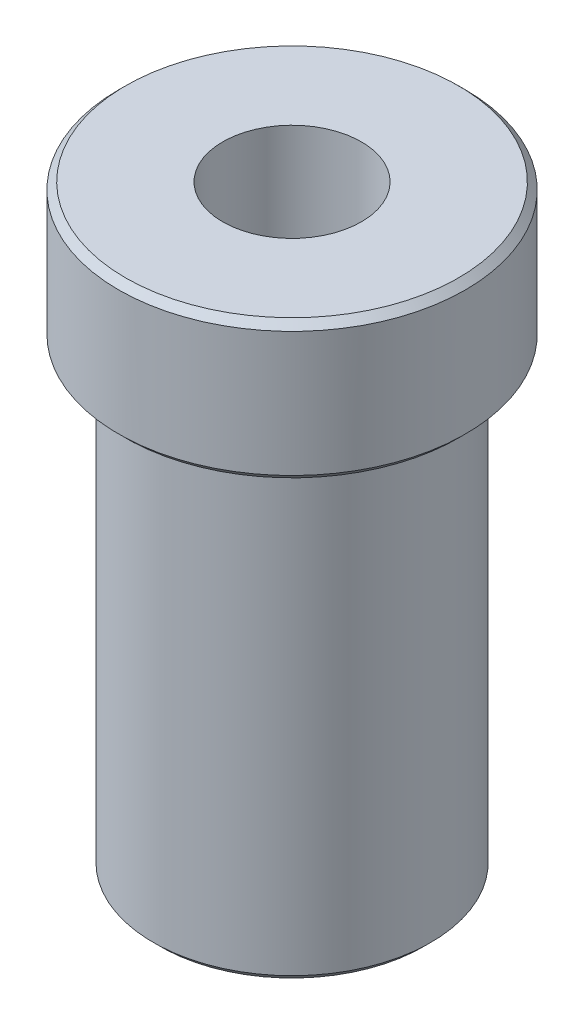
from build123d import *

# Parameters (mm, degrees)
SKETCH2_R          = 5
CUT_EXTRUDE1_DEPTH = 44
CHAMFER1_SIZE      = 0.5


with BuildPart() as part:
    # Sketch1 → Revolve1 (revolve)
    with BuildSketch(Plane.XY):
        Polygon((-2.846534653, 10), (9.653465347, 10), (9.653465347, 0), (7.153465347, 0), (7.153465347, -33), (-2.846534653, -33), align=None)
    revolve(axis=Axis((-2.846534653, -33, 0), (0, 1, 0)))

    # Sketch2 → Cut-Extrude1 (cut, through all)
    with BuildSketch(Plane(origin=(0, 10, 0), x_dir=(1, 0, 0), z_dir=(0, 1, 0))):
        with Locations((-2.846534653, 0)):
            Circle(SKETCH2_R)
    extrude(amount=-CUT_EXTRUDE1_DEPTH, mode=Mode.SUBTRACT)

    # Chamfer1
    chamfer1_edges = [part.edges().sort_by_distance(p)[0] for p in [
        (-12.846534653, -33, 0),
        (-15.346534653, 0, 0),
        (-15.346534653, 10, 0),
    ]]
    chamfer(chamfer1_edges, length=CHAMFER1_SIZE)


solid = part.part
